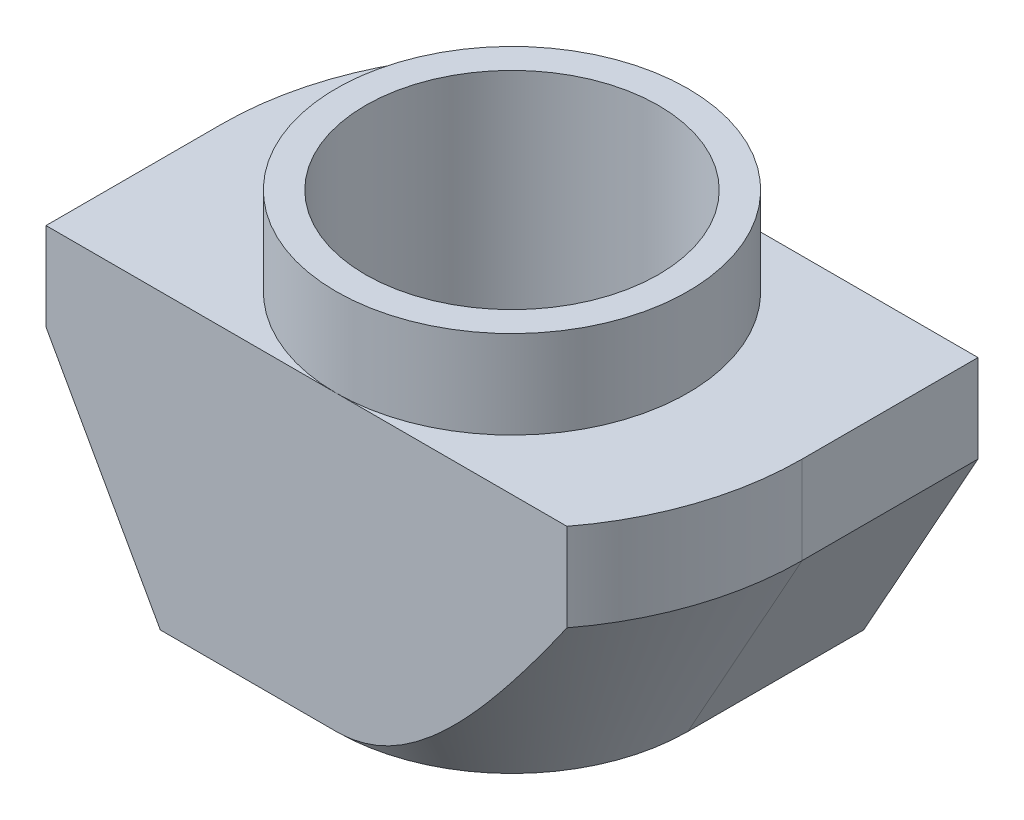
from build123d import *

# Parameters (mm, degrees)
EXTRUDE_1_DEPTH       = 3
HOLE_WIZARD_M61_D     = 5
HOLE_WIZARD_M61_DEPTH = 6.5
SKETCH_4_OUTSIDE_W    = 14.556
SKETCH_4_OUTSIDE_H    = 10.656
SKETCH_4_OUTSIDE_R    = 3
CUT_EXTRUDE_1_DEPTH   = 1.5
CUT_EXTRUDE_2_DEPTH   = 6


with BuildPart() as part:
    # Эскиз1 → Бобышка-Вытянуть1 (new body, symmetric)
    with BuildSketch(Plane.XY):
        Polygon((3, 0), (-3, 0), (-3, -1.5), (-4.95, -1.5), (-4.95, -6.5), (4.95, -6.5), (4.95, -1.5), (3, -1.5), align=None)
    extrude(amount=EXTRUDE_1_DEPTH, both=True)

    # Отверстие обработанное метчиком M61
    with Locations(Plane(origin=(0, 0, 0), x_dir=(1, 0, 0), z_dir=(0, 1, 0))):
        with Locations((0, 0)):
            Hole(HOLE_WIZARD_M61_D / 2, depth=HOLE_WIZARD_M61_DEPTH)

    # Эскиз4 outside → Вырез-Вытянуть1 (cut)
    with BuildSketch(Plane(origin=(0, 0, 0), x_dir=(1, 0, 0), z_dir=(0, 1, 0))):
        Rectangle(SKETCH_4_OUTSIDE_W, SKETCH_4_OUTSIDE_H)
        with Locations(Location((0, 0, 0), (0, 0, 270))):  # turned: the seam where the file's is
            Circle(SKETCH_4_OUTSIDE_R, mode=Mode.SUBTRACT)
    extrude(amount=-CUT_EXTRUDE_1_DEPTH, mode=Mode.SUBTRACT)

    # Эскиз5 → Вырез-Вытянуть2 (cut, through all)
    with BuildSketch(Plane(origin=(0, -1.5, 0), x_dir=(1, 0, 0), z_dir=(0, 1, 0))):
        with BuildLine():
            Line((-4.95, 0), (-4.95, 3))
            Line((-4.95, 3), (-3.937321425, 3))
            ThreePointArc((-3.937321425, 3), (-4.690002188, 1.583154912), (-4.95, 0))
        make_face()
        with BuildLine():
            Line((4.95, 0), (4.95, -3))
            Line((4.95, -3), (3.937321425, -3))
            ThreePointArc((3.937321425, -3), (4.690002188, -1.583154912), (4.95, 0))
        make_face()
    extrude(amount=-CUT_EXTRUDE_2_DEPTH, mode=Mode.SUBTRACT)

    # Вырез-По траектории1: sweep along a path in Эскиз7
    with BuildLine(Plane.XZ.offset(6.5)) as sweep_1_path:
        Line((0, 4.95), (-4.95, 4.95))
        Line((-4.95, 4.95), (-4.95, 0))
        ThreePointArc((-4.95, 0), (-3.500178567, -3.500178567), (0, -4.95))
        Line((0, -4.95), (4.95, -4.95))
        Line((4.95, -4.95), (4.95, 0))
        ThreePointArc((4.95, 0), (3.500178567, 3.500178567), (0, 4.95))
    # Эскиз6 → Вырез-По траектории1 (sweep, cut)
    with BuildSketch(Plane.XY.offset(3)):
        Polygon((-4.95, -3), (-4.95, -6.5), (-3, -6.5), align=None)
    sweep(path=sweep_1_path.line, transition=Transition.RIGHT, mode=Mode.SUBTRACT)


solid = part.part
